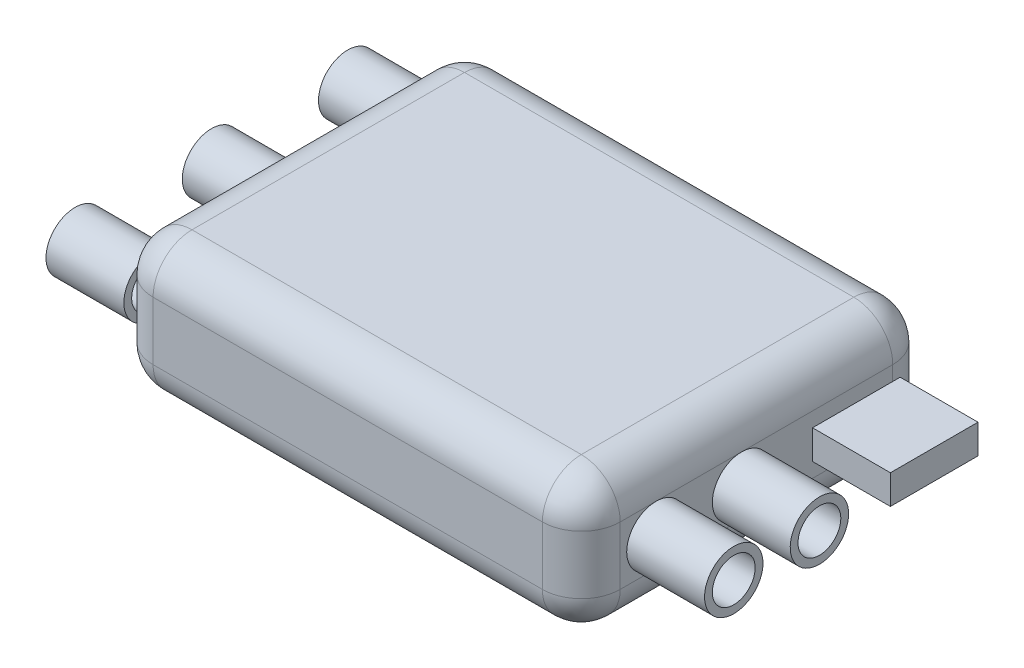
from build123d import *

# Parameters (mm, degrees)
BOSS_EXTRUDE1_DEPTH = 7
FILLET1_R           = 2
SKETCH2_R           = 1.5
SKETCH2_R_2         = 1.1
BOSS_EXTRUDE2_DEPTH = 4
SKETCH3_R           = 1.5
SKETCH3_R_2         = 1.1
SKETCH3_W           = 4.5
SKETCH3_H           = 1.5
BOSS_EXTRUDE3_DEPTH = 4


with BuildPart() as part:
    # Sketch1 → Boss-Extrude1 (new body)
    with BuildSketch(Plane(origin=(0, 0, 0), x_dir=(1, 0, 0), z_dir=(0, 1, 0))):
        with BuildLine():
            Line((-10, -9), (10, -9))
            ThreePointArc((10, -9), (11.414213562, -8.414213562), (12, -7))
            Line((12, -7), (12, 7))
            ThreePointArc((12, 7), (11.414213562, 8.414213562), (10, 9))
            Line((10, 9), (-10, 9))
            ThreePointArc((-10, 9), (-11.414213562, 8.414213562), (-12, 7))
            Line((-12, 7), (-12, -7))
            ThreePointArc((-12, -7), (-11.414213562, -8.414213562), (-10, -9))
        make_face()
    extrude(amount=BOSS_EXTRUDE1_DEPTH)

    # Fillet1
    fillet1_edges = [part.edges().sort_by_distance(p)[0] for p in [
        (12, 0, 0),
        (11.414213562, 0, 8.414213562),
        (0, 0, 9),
        (-11.414213562, 0, 8.414213562),
        (11.414213562, 7, 8.414213562),
        (12, 7, 0),
        (11.414213562, 7, -8.414213562),
        (0, 7, -9),
        (-11.414213562, 7, -8.414213562),
        (-12, 7, 0),
        (-11.414213562, 7, 8.414213562),
        (-12, 0, 0),
        (0, 7, 9),
        (-11.414213562, 0, -8.414213562),
        (0, 0, -9),
        (11.414213562, 0, -8.414213562),
    ]]
    fillet(fillet1_edges, radius=FILLET1_R)

    # Sketch2 → Boss-Extrude2 (add)
    with BuildSketch(Plane.ZY.offset(12)):
        with Locations((-7, 3.5)):
            Circle(SKETCH2_R)
        with Locations((-7, 3.5)):
            Circle(SKETCH2_R_2, mode=Mode.SUBTRACT)
        with Locations((0, 3.5)):
            Circle(SKETCH2_R)
        with Locations((0, 3.5)):
            Circle(SKETCH2_R_2, mode=Mode.SUBTRACT)
        with Locations((7, 3.5)):
            Circle(SKETCH2_R)
        with Locations((7, 3.5)):
            Circle(SKETCH2_R_2, mode=Mode.SUBTRACT)
    extrude(amount=BOSS_EXTRUDE2_DEPTH)

    # Sketch3 → Boss-Extrude3 (add)
    with BuildSketch(Plane(origin=(12, 0, 0), x_dir=(0, 0, -1), z_dir=(1, 0, 0))):
        with Locations((-5.167527067, 3.5)):
            Circle(SKETCH3_R)
        with Locations((-5.167527067, 3.5)):
            Circle(SKETCH3_R_2, mode=Mode.SUBTRACT)
        with Locations((-0.767527067, 3.5)):
            Circle(SKETCH3_R)
        with Locations((-0.767527067, 3.5)):
            Circle(SKETCH3_R_2, mode=Mode.SUBTRACT)
        with Locations((5.129819771, 3.5)):
            Rectangle(SKETCH3_W, SKETCH3_H)
    extrude(amount=BOSS_EXTRUDE3_DEPTH)


solid = part.part
